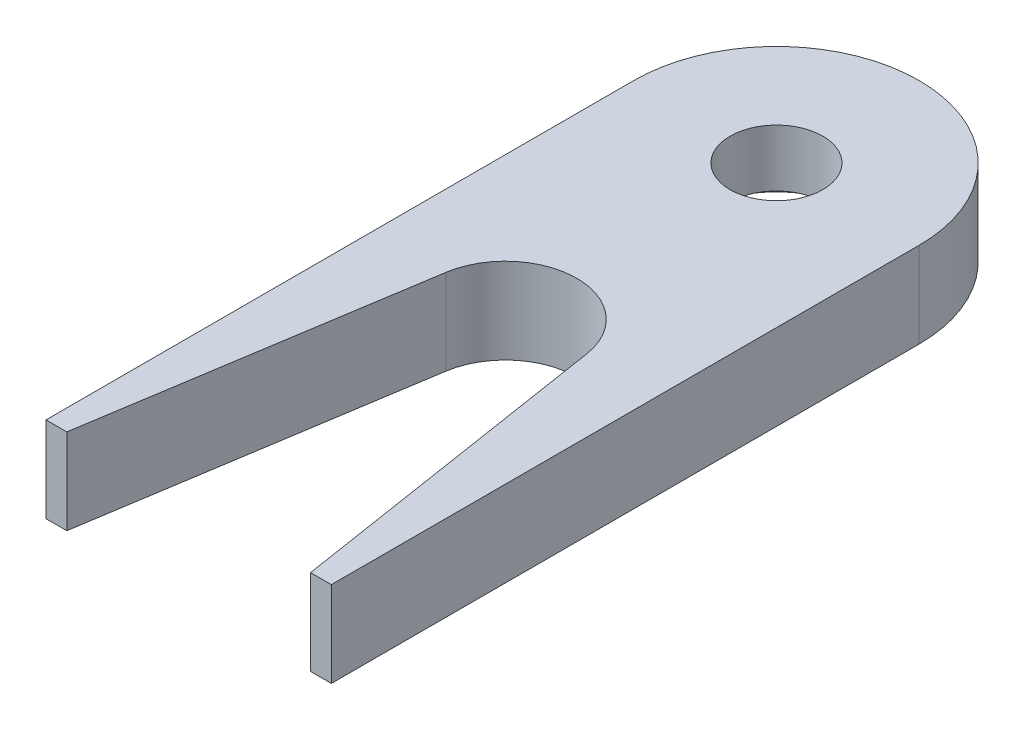
from build123d import *

# Parameters (mm, degrees)
SKETCH_1_R          = 3.25
EXTRUDE_1_DEPTH     = 6
SKETCH_2_R          = 6
CUT_EXTRUDE_1_DEPTH = 2


with BuildPart() as part:
    # Эскиз1 → Бобышка-Вытянуть1 (new body)
    with BuildSketch(Plane(origin=(0, 0, 0), x_dir=(1, 0, 0), z_dir=(0, 1, 0))):
        with BuildLine():
            Line((-4.939643838, -18.225455779), (-8.542011418, -41.199499519))
            Line((-8.542011418, -41.199499519), (-10, -41.199499519))
            Line((-10, -41.199499519), (-10, 0))
            ThreePointArc((-10, 0), (0, 10), (10, 0))
            Line((10, 0), (10, -41.199499519))
            Line((10, -41.199499519), (8.542011418, -41.199499519))
            Line((8.542011418, -41.199499519), (4.939643838, -18.225455779))
            ThreePointArc((4.939643838, -18.225455779), (0, -14), (-4.939643838, -18.225455779))
        make_face()
        Circle(SKETCH_1_R, mode=Mode.SUBTRACT)
    extrude(amount=EXTRUDE_1_DEPTH)

    # Эскиз2 → Вырез-Вытянуть1 (cut)
    with BuildSketch(Plane.XZ):
        Circle(SKETCH_2_R)
    extrude(amount=-CUT_EXTRUDE_1_DEPTH, mode=Mode.SUBTRACT)


solid = part.part
